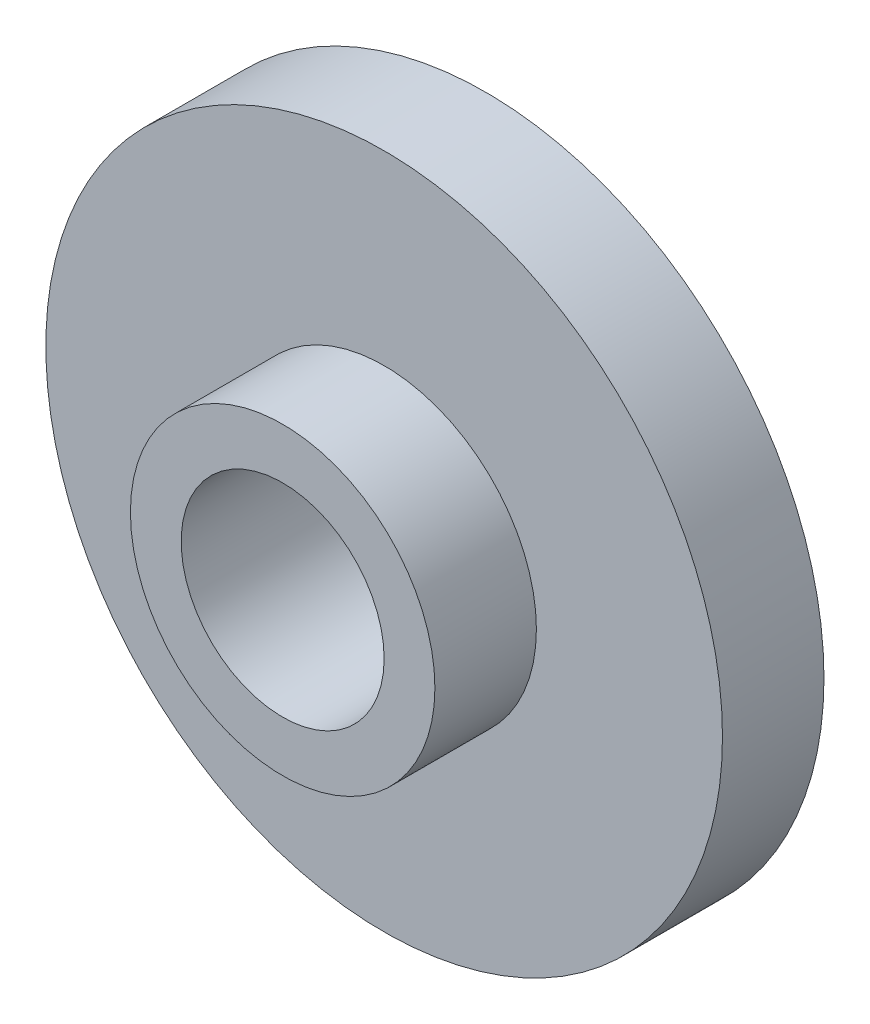
from build123d import *

# Parameters (mm, degrees)
SKETCH1_R           = 10
SKETCH1_R_2         = 3
BOSS_EXTRUDE1_DEPTH = 3
SKETCH2_R           = 4.5
SKETCH2_R_2         = 3
BOSS_EXTRUDE2_DEPTH = 3


with BuildPart() as part:
    # Sketch1 → Boss-Extrude1 (new body)
    with BuildSketch(Plane.XY):
        Circle(SKETCH1_R)
        Circle(SKETCH1_R_2, mode=Mode.SUBTRACT)
    extrude(amount=BOSS_EXTRUDE1_DEPTH)

    # Sketch2 → Boss-Extrude2 (add)
    with BuildSketch(Plane.XY.offset(3)):
        Circle(SKETCH2_R)
        Circle(SKETCH2_R_2, mode=Mode.SUBTRACT)
    extrude(amount=BOSS_EXTRUDE2_DEPTH)


solid = part.part
